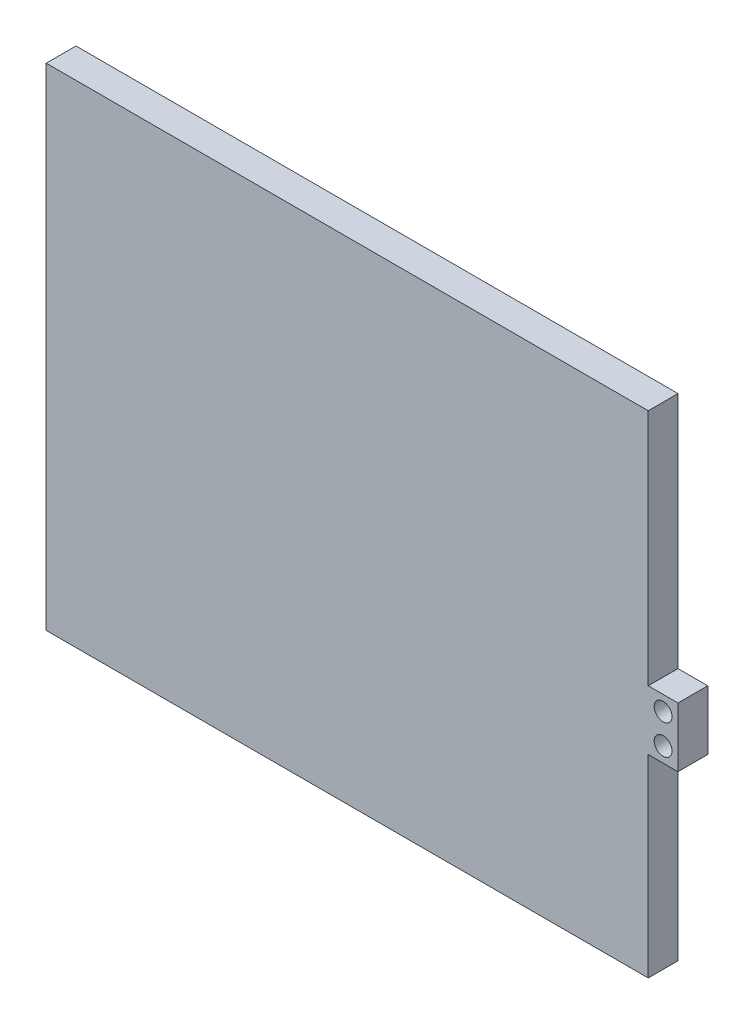
from build123d import *

# Parameters (mm, degrees)
SKETCH2_W           = 256.794
SKETCH2_H           = 196.85
BOSS_EXTRUDE1_DEPTH = 12.7
SKETCH3_W           = 12.7
SKETCH3_H           = 25.4
BOSS_EXTRUDE2_DEPTH = 12.7
SKETCH4_R           = 3.81
CUT_EXTRUDE1_DEPTH  = 12.7
SKETCH5_W           = 256.794
SKETCH5_H           = 12.7
BOSS_EXTRUDE3_DEPTH = 12.7


with BuildPart() as part:
    # Sketch2 → Boss-Extrude1 (new body)
    with BuildSketch(Plane.XY):
        with Locations((5.975438209, -11.247712934)):
            Rectangle(SKETCH2_W, SKETCH2_H)
    extrude(amount=BOSS_EXTRUDE1_DEPTH)

    # Sketch3 → Boss-Extrude2 (add)
    with BuildSketch(Plane(origin=(134.372438209, 0, 0), x_dir=(0, 0, -1), z_dir=(1, 0, 0))):
        with Locations((-6.35, -14.422712934)):
            Rectangle(SKETCH3_W, SKETCH3_H)
    extrude(amount=BOSS_EXTRUDE2_DEPTH)

    # Sketch4 → Cut-Extrude1 (cut)
    with BuildSketch(Plane(origin=(0, 0, 0), x_dir=(-1, 0, 0), z_dir=(0, 0, -1))):
        with Locations((-140.722438209, -8.072712934)):
            Circle(SKETCH4_R)
        with Locations((-140.722438209, -20.772712934)):
            Circle(SKETCH4_R)
    extrude(amount=-CUT_EXTRUDE1_DEPTH, mode=Mode.SUBTRACT)

    # Sketch5 → Boss-Extrude3 (add)
    with BuildSketch(Plane(origin=(0, 87.177287066, 0), x_dir=(1, 0, 0), z_dir=(0, 1, 0))):
        with Locations((5.975438209, -6.35)):
            Rectangle(SKETCH5_W, SKETCH5_H)
    extrude(amount=BOSS_EXTRUDE3_DEPTH)


solid = part.part
